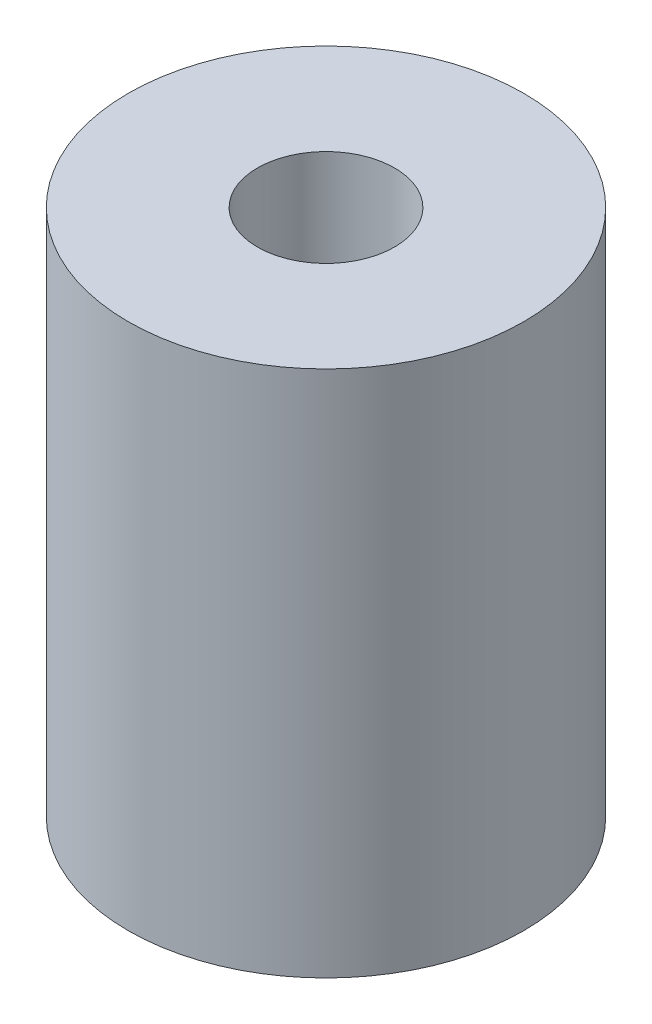
from build123d import *

# Parameters (mm, degrees)
SKETCH1_R           = 9.525
SKETCH1_R_2         = 3.302
BOSS_EXTRUDE1_DEPTH = 25.4


with BuildPart() as part:
    # Sketch1 → Boss-Extrude1 (new body)
    with BuildSketch(Plane(origin=(0, 0, 0), x_dir=(1, 0, 0), z_dir=(0, 1, 0))):
        Circle(SKETCH1_R)
        Circle(SKETCH1_R_2, mode=Mode.SUBTRACT)
    extrude(amount=BOSS_EXTRUDE1_DEPTH)


solid = part.part
